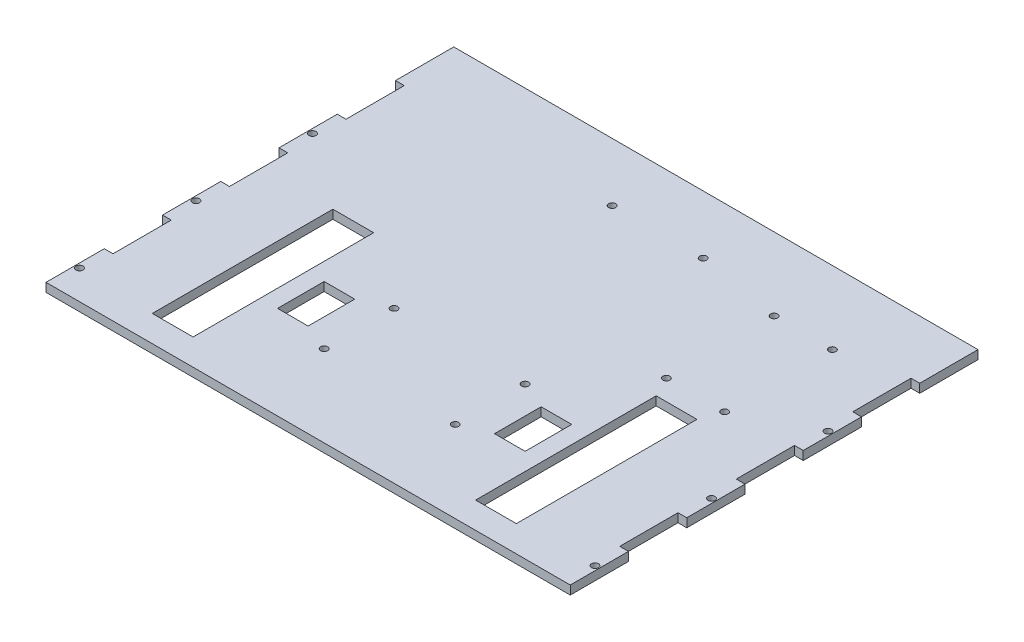
from build123d import *

# Parameters (mm, degrees)
SKETCH1_R           = 1.524
SKETCH1_W           = 13.335
SKETCH1_H           = 20.32
SKETCH1_W_2         = 17.78
SKETCH1_H_2         = 78.74
BOSS_EXTRUDE1_DEPTH = 3.81


with BuildPart() as part:
    # Sketch1 → Boss-Extrude1 (new body)
    with BuildSketch(Plane(origin=(0, 0, 0), x_dir=(1, 0, 0), z_dir=(0, 1, 0))):
        Polygon((-114.3, -88.9), (114.3, -88.9), (114.3, -63.5), (110.49, -63.5), (110.49, -38.1), (114.3, -38.1), (114.3, -12.7), (110.49, -12.7), (110.49, 12.7), (114.3, 12.7), (114.3, 38.1), (110.49, 38.1), (110.49, 63.5), (114.3, 63.5), (114.3, 88.9), (-114.3, 88.9), (-114.3, 63.5), (-110.49, 63.5), (-110.49, 38.1), (-114.3, 38.1), (-114.3, 12.7), (-110.49, 12.7), (-110.49, -12.7), (-114.3, -12.7), (-114.3, -38.1), (-110.49, -38.1), (-110.49, -63.5), (-114.3, -63.5), align=None)
        with Locations((-28.575, -22.86)):
            Circle(SKETCH1_R, mode=Mode.SUBTRACT)
        with Locations((-28.575, -53.34)):
            Circle(SKETCH1_R, mode=Mode.SUBTRACT)
        with Locations((28.575, -53.34)):
            Circle(SKETCH1_R, mode=Mode.SUBTRACT)
        with Locations((28.575, -22.86)):
            Circle(SKETCH1_R, mode=Mode.SUBTRACT)
        with Locations((57.15, 57.15)):
            Circle(SKETCH1_R, mode=Mode.SUBTRACT)
        with Locations((57.15, 10.16)):
            Circle(SKETCH1_R, mode=Mode.SUBTRACT)
        with Locations((82.55, 10.16)):
            Circle(SKETCH1_R, mode=Mode.SUBTRACT)
        with Locations((82.55, 57.15)):
            Circle(SKETCH1_R, mode=Mode.SUBTRACT)
        with Locations((112.395, -76.2)):
            Circle(SKETCH1_R, mode=Mode.SUBTRACT)
        with Locations((-112.395, -76.2)):
            Circle(SKETCH1_R, mode=Mode.SUBTRACT)
        with Locations((-112.395, -25.4)):
            Circle(SKETCH1_R, mode=Mode.SUBTRACT)
        with Locations((-112.395, 25.4)):
            Circle(SKETCH1_R, mode=Mode.SUBTRACT)
        with Locations((112.395, -25.4)):
            Circle(SKETCH1_R, mode=Mode.SUBTRACT)
        with Locations((112.395, 25.4)):
            Circle(SKETCH1_R, mode=Mode.SUBTRACT)
        with Locations((-19.8501, 63.5)):
            Circle(SKETCH1_R, mode=Mode.SUBTRACT)
        with Locations((19.8501, 63.5)):
            Circle(SKETCH1_R, mode=Mode.SUBTRACT)
        with Locations((-47.3075, -38.1)):
            Rectangle(SKETCH1_W, SKETCH1_H, mode=Mode.SUBTRACT)
        with Locations((70.485, -38.1)):
            Rectangle(SKETCH1_W_2, SKETCH1_H_2, mode=Mode.SUBTRACT)
        with Locations((-70.485, -38.1)):
            Rectangle(SKETCH1_W_2, SKETCH1_H_2, mode=Mode.SUBTRACT)
        with Locations((47.3075, -38.1)):
            Rectangle(SKETCH1_W, SKETCH1_H, mode=Mode.SUBTRACT)
    extrude(amount=BOSS_EXTRUDE1_DEPTH)


solid = part.part
